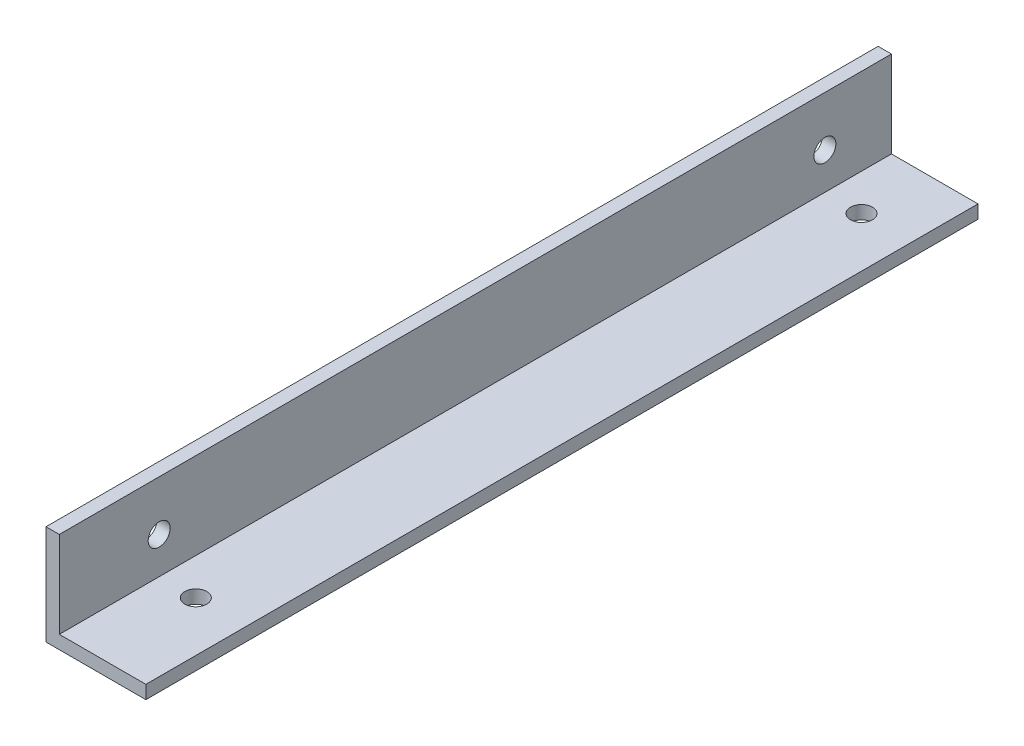
from build123d import *

# Parameters (mm, degrees)
EXTRUDE_1_DEPTH          = 125
M4X0_7_1_D               = 3.3
M4X0_7_1_DEPTH           = 11.5
M4X0_7_1_TIP             = 0.991420021
M4X0_7_1_ON_FACE_2_D     = 3.3
M4X0_7_1_ON_FACE_2_DEPTH = 11.5
M4X0_7_1_ON_FACE_2_TIP   = 0.991420021


with BuildPart() as part:
    # ｽｹｯﾁ1 → ﾎﾞｽ - 押し出し1 (new body)
    with BuildSketch(Plane.XY):
        Polygon((0, 0), (15, 0), (15, 2), (2, 2), (2, 15), (0, 15), align=None)
    extrude(amount=EXTRUDE_1_DEPTH)

    # M4x0.7 ねじ穴1
    with Locations(Plane(origin=(7.5, 0, 10), x_dir=(0, 0, -1), z_dir=(0, -1, 0))):
        with Locations((0, 0), (-100, 0)):
            Hole(M4X0_7_1_D / 2, depth=M4X0_7_1_DEPTH)
            with Locations((0, 0, -(M4X0_7_1_DEPTH + M4X0_7_1_TIP / 2))):  # 118° drill point
                Cone(0, M4X0_7_1_D / 2, M4X0_7_1_TIP, mode=Mode.SUBTRACT)

    # M4x0.7 ねじ穴1 on face 2
    with Locations(Plane(origin=(0, 7.5, 110), x_dir=(0, 0, -1), z_dir=(-1, 0, 0))):
        with Locations((0, 0), (100, 0)):
            Hole(M4X0_7_1_ON_FACE_2_D / 2, depth=M4X0_7_1_ON_FACE_2_DEPTH)
            with Locations((0, 0, -(M4X0_7_1_ON_FACE_2_DEPTH + M4X0_7_1_ON_FACE_2_TIP / 2))):  # 118° drill point
                Cone(0, M4X0_7_1_ON_FACE_2_D / 2, M4X0_7_1_ON_FACE_2_TIP, mode=Mode.SUBTRACT)


solid = part.part
